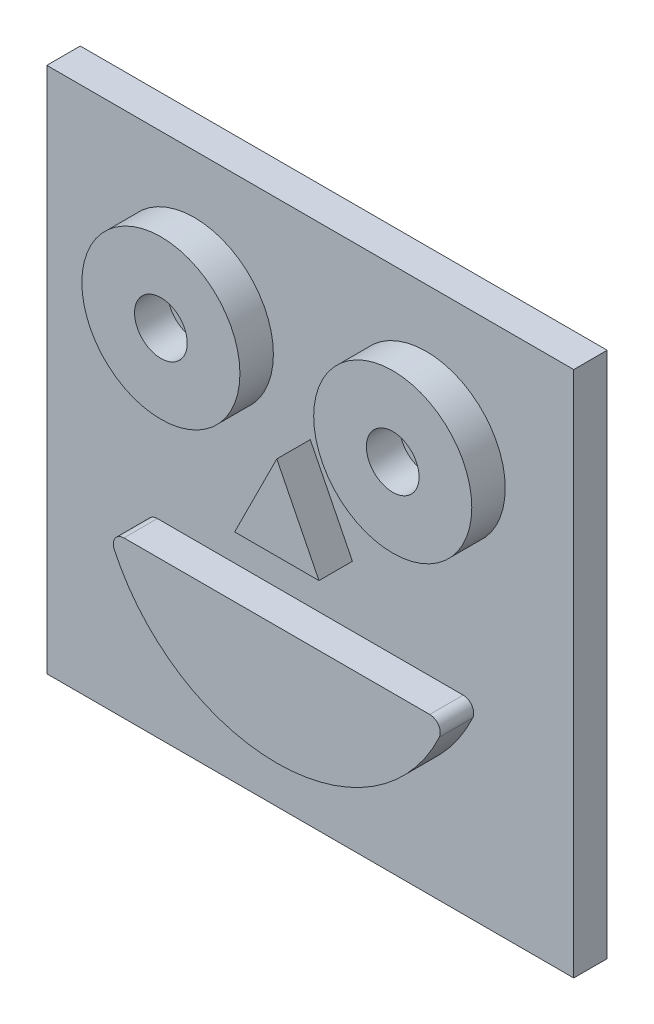
from build123d import *

# Parameters (mm, degrees)
SKETCH1_W           = 50
SKETCH1_H           = 50
BOSS_EXTRUDE1_DEPTH = 3.175
SKETCH2_R           = 7.5
SKETCH2_R_2         = 2.5
BOSS_EXTRUDE2_DEPTH = 3.175
FILLET1_R           = 1


with BuildPart() as part:
    # Sketch1 → Boss-Extrude1 (new body)
    with BuildSketch(Plane.XY):
        Rectangle(SKETCH1_W, SKETCH1_H)
    extrude(amount=BOSS_EXTRUDE1_DEPTH)

    # Sketch2 → Boss-Extrude2 (add)
    with BuildSketch(Plane.XY.offset(3.175)):
        with Locations((-11, 12)):
            Circle(SKETCH2_R)
        with Locations((-11, 12)):
            Circle(SKETCH2_R_2, mode=Mode.SUBTRACT)
        with Locations((11, 12)):
            Circle(SKETCH2_R)
        with Locations((11, 12)):
            Circle(SKETCH2_R_2, mode=Mode.SUBTRACT)
        with BuildLine():
            Line((-16, -7), (16, -7))
            ThreePointArc((16, -7), (0, -18.255437353), (-16, -7))
        make_face()
        Polygon((0, 6.744562647), (4, -1.255437353), (-4, -1.255437353), align=None)
    extrude(amount=BOSS_EXTRUDE2_DEPTH)

    # Fillet1
    fillet1_edges = [part.edges().sort_by_distance(p)[0] for p in [
        (-16, -7, 4.7625),
        (16, -7, 4.7625),
    ]]
    fillet(fillet1_edges, radius=FILLET1_R)


solid = part.part
